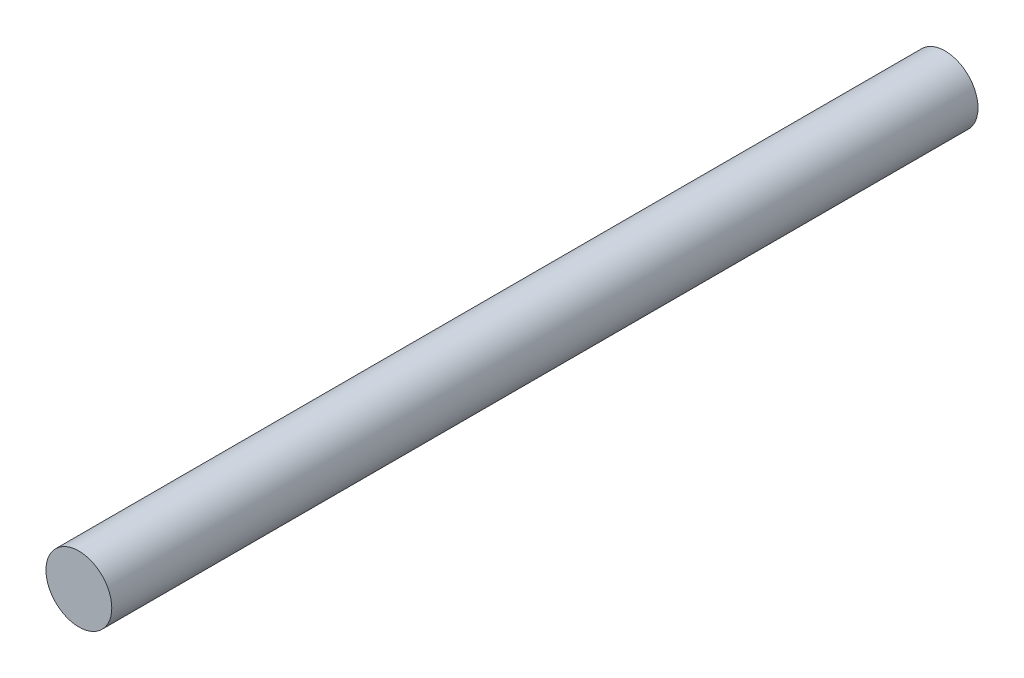
from build123d import *

# Parameters (mm, degrees)
SKETCH_1_R      = 4
EXTRUDE_1_DEPTH = 105.25


with BuildPart() as part:
    # 草图1 → 凸台-拉伸1 (new body)
    with BuildSketch(Plane.XY):
        with Locations((2.788805167, 15.198988159)):
            Circle(SKETCH_1_R)
    extrude(amount=EXTRUDE_1_DEPTH)


solid = part.part
